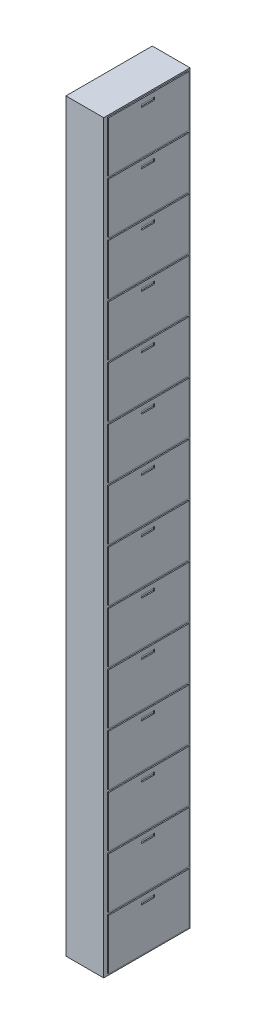
from build123d import *

# Parameters (mm, degrees)
SKETCH1_W           = 350
SKETCH1_H           = 6900
BOSS_EXTRUDE1_DEPTH = 800
SKETCH3_W           = 743.632052548
SKETCH3_H           = 470
SKETCH3_W_2         = 121.072841775
SKETCH3_H_2         = 25.802408902
BOSS_EXTRUDE3_DEPTH = 10


with BuildPart() as part:
    # Sketch1 → Boss-Extrude1 (new body)
    with BuildSketch(Plane.XY):
        with Locations((38.061970043, 729.986327315)):
            Rectangle(SKETCH1_W, SKETCH1_H)
    extrude(amount=BOSS_EXTRUDE1_DEPTH)

    # Sketch3 → Boss-Extrude3 (add)
    with BuildSketch(Plane(origin=(213.061970043, 0, 0), x_dir=(0, 0, -1), z_dir=(1, 0, 0))):
        with Locations((-391.816026274, -2465.013672685)):
            Rectangle(SKETCH3_W, SKETCH3_H)
        with Locations((-401.128332344, -2287.011976611)):
            Rectangle(SKETCH3_W_2, SKETCH3_H_2, mode=Mode.SUBTRACT)
        with Locations((-391.816026274, -1481.013672685)):
            Rectangle(SKETCH3_W, SKETCH3_H)
        with Locations((-401.128332344, -1303.011976611)):
            Rectangle(SKETCH3_W_2, SKETCH3_H_2, mode=Mode.SUBTRACT)
        with Locations((-391.816026274, -1973.013672685)):
            Rectangle(SKETCH3_W, SKETCH3_H)
        with Locations((-401.128332344, -1795.011976611)):
            Rectangle(SKETCH3_W_2, SKETCH3_H_2, mode=Mode.SUBTRACT)
        with Locations((-391.816026274, -989.013672685)):
            Rectangle(SKETCH3_W, SKETCH3_H)
        with Locations((-401.128332344, -811.011976611)):
            Rectangle(SKETCH3_W_2, SKETCH3_H_2, mode=Mode.SUBTRACT)
        with Locations((-391.816026274, -497.013672685)):
            Rectangle(SKETCH3_W, SKETCH3_H)
        with Locations((-401.128332344, -319.011976611)):
            Rectangle(SKETCH3_W_2, SKETCH3_H_2, mode=Mode.SUBTRACT)
        with Locations((-391.816026274, -5.013672685)):
            Rectangle(SKETCH3_W, SKETCH3_H)
        with Locations((-401.128332344, 172.988023389)):
            Rectangle(SKETCH3_W_2, SKETCH3_H_2, mode=Mode.SUBTRACT)
        with Locations((-391.816026274, 486.986327315)):
            Rectangle(SKETCH3_W, SKETCH3_H)
        with Locations((-401.128332344, 664.988023389)):
            Rectangle(SKETCH3_W_2, SKETCH3_H_2, mode=Mode.SUBTRACT)
        with Locations((-391.816026274, 978.986327315)):
            Rectangle(SKETCH3_W, SKETCH3_H)
        with Locations((-401.128332344, 1156.988023389)):
            Rectangle(SKETCH3_W_2, SKETCH3_H_2, mode=Mode.SUBTRACT)
        with Locations((-391.816026274, 1470.986327315)):
            Rectangle(SKETCH3_W, SKETCH3_H)
        with Locations((-401.128332344, 1648.988023389)):
            Rectangle(SKETCH3_W_2, SKETCH3_H_2, mode=Mode.SUBTRACT)
        with Locations((-391.816026274, 1962.986327315)):
            Rectangle(SKETCH3_W, SKETCH3_H)
        with Locations((-401.128332344, 2140.988023389)):
            Rectangle(SKETCH3_W_2, SKETCH3_H_2, mode=Mode.SUBTRACT)
        with Locations((-391.816026274, 2454.986327315)):
            Rectangle(SKETCH3_W, SKETCH3_H)
        with Locations((-401.128332344, 2632.988023389)):
            Rectangle(SKETCH3_W_2, SKETCH3_H_2, mode=Mode.SUBTRACT)
        with Locations((-391.816026274, 2946.986327315)):
            Rectangle(SKETCH3_W, SKETCH3_H)
        with Locations((-401.128332344, 3124.988023389)):
            Rectangle(SKETCH3_W_2, SKETCH3_H_2, mode=Mode.SUBTRACT)
        with Locations((-391.816026274, 3438.986327315)):
            Rectangle(SKETCH3_W, SKETCH3_H)
        with Locations((-401.128332344, 3616.988023389)):
            Rectangle(SKETCH3_W_2, SKETCH3_H_2, mode=Mode.SUBTRACT)
        with Locations((-391.816026274, 3930.986327315)):
            Rectangle(SKETCH3_W, SKETCH3_H)
        with Locations((-401.128332344, 4108.988023389)):
            Rectangle(SKETCH3_W_2, SKETCH3_H_2, mode=Mode.SUBTRACT)
    extrude(amount=BOSS_EXTRUDE3_DEPTH)


solid = part.part
